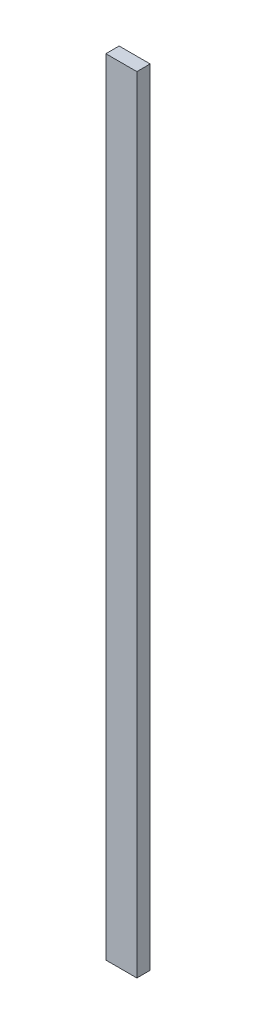
from build123d import *

# Parameters (mm, degrees)
SKETCH1_W           = 88.9
SKETCH1_H           = 38.1
BOSS_EXTRUDE1_DEPTH = 2247.9


with BuildPart() as part:
    # Sketch1 → Boss-Extrude1 (new body)
    with BuildSketch(Plane(origin=(0, 0, 0), x_dir=(1, 0, 0), z_dir=(0, 1, 0))):
        Rectangle(SKETCH1_W, SKETCH1_H)
    extrude(amount=BOSS_EXTRUDE1_DEPTH)


solid = part.part
